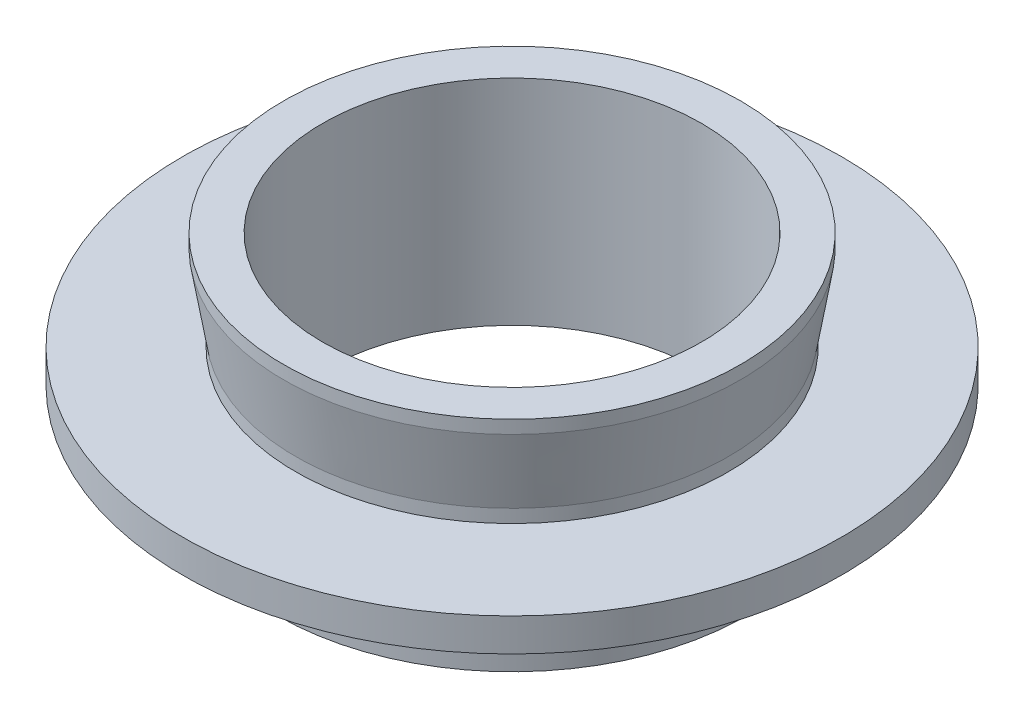
from build123d import *


with BuildPart() as part:
    # 草图1 → 旋转1 (revolve)
    with BuildSketch(Plane.XY, mode=Mode.PRIVATE) as revolve_1_sk:
        Polygon((-11.5, 0), (-11.5, 13), (-13.865, 13), (-13.865, 12.2), (-13.135, 7.8), (-13.135, 7), (-20, 7), (-20, 5), (-14, 5), (-14, 4), (-14.25, 4), (-14.25, 0), align=None)
    revolve(revolve_1_sk.sketch.rotate(Axis((0, 0, 0), (0, 1, 0)), 270), axis=Axis((0, 0, 0), (0, 1, 0)))  # turned: the seam where the file's is


solid = part.part
